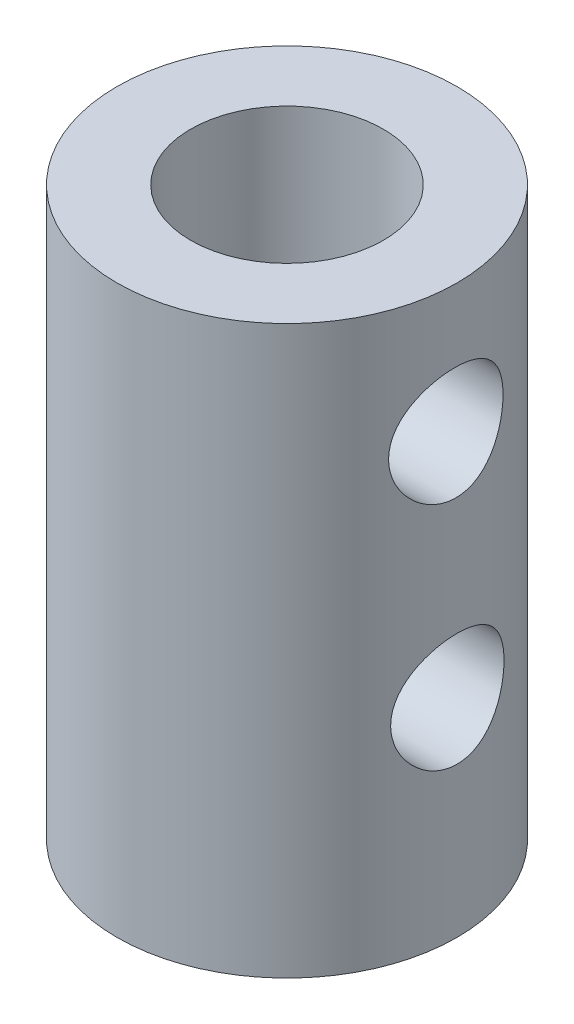
from build123d import *

# Parameters (mm, degrees)
SKETCH1_R           = 6
BOSS_EXTRUDE1_DEPTH = 20
SKETCH2_R           = 3.4
CUT_EXTRUDE1_DEPTH  = 13.55
SKETCH5_W           = 1.550685087
SKETCH5_H           = 7.184215806
BOSS_EXTRUDE2_DEPTH = 13.55
SKETCH6_R           = 2
CUT_EXTRUDE2_DEPTH  = 13.55


with BuildPart() as part:
    # Sketch1 → Boss-Extrude1 (new body)
    with BuildSketch(Plane(origin=(0, 0, 0), x_dir=(1, 0, 0), z_dir=(0, 1, 0))):
        Circle(SKETCH1_R)
    extrude(amount=BOSS_EXTRUDE1_DEPTH)

    # Sketch2 → Cut-Extrude1 (cut)
    with BuildSketch(Plane(origin=(0, 20, 0), x_dir=(1, 0, 0), z_dir=(0, 1, 0))):
        Circle(SKETCH2_R)
    extrude(amount=-CUT_EXTRUDE1_DEPTH, mode=Mode.SUBTRACT)

    # Sketch5 → Boss-Extrude2 (add)
    with BuildSketch(Plane(origin=(0, 18.26, 0), x_dir=(1, 0, 0), z_dir=(0, 1, 0))):
        with Locations((3.375342544, 0.020519704)):
            Rectangle(SKETCH5_W, SKETCH5_H)
    extrude(amount=-BOSS_EXTRUDE2_DEPTH)

    # Sketch6 → Cut-Extrude2 (cut)
    with BuildSketch(Plane.ZY.offset(-2.6)):
        with Locations((0.054169736, 15.452187313)):
            Circle(SKETCH6_R)
        with Locations((0, 7.29207964)):
            Circle(SKETCH6_R)
    extrude(amount=-CUT_EXTRUDE2_DEPTH, mode=Mode.SUBTRACT)


solid = part.part
